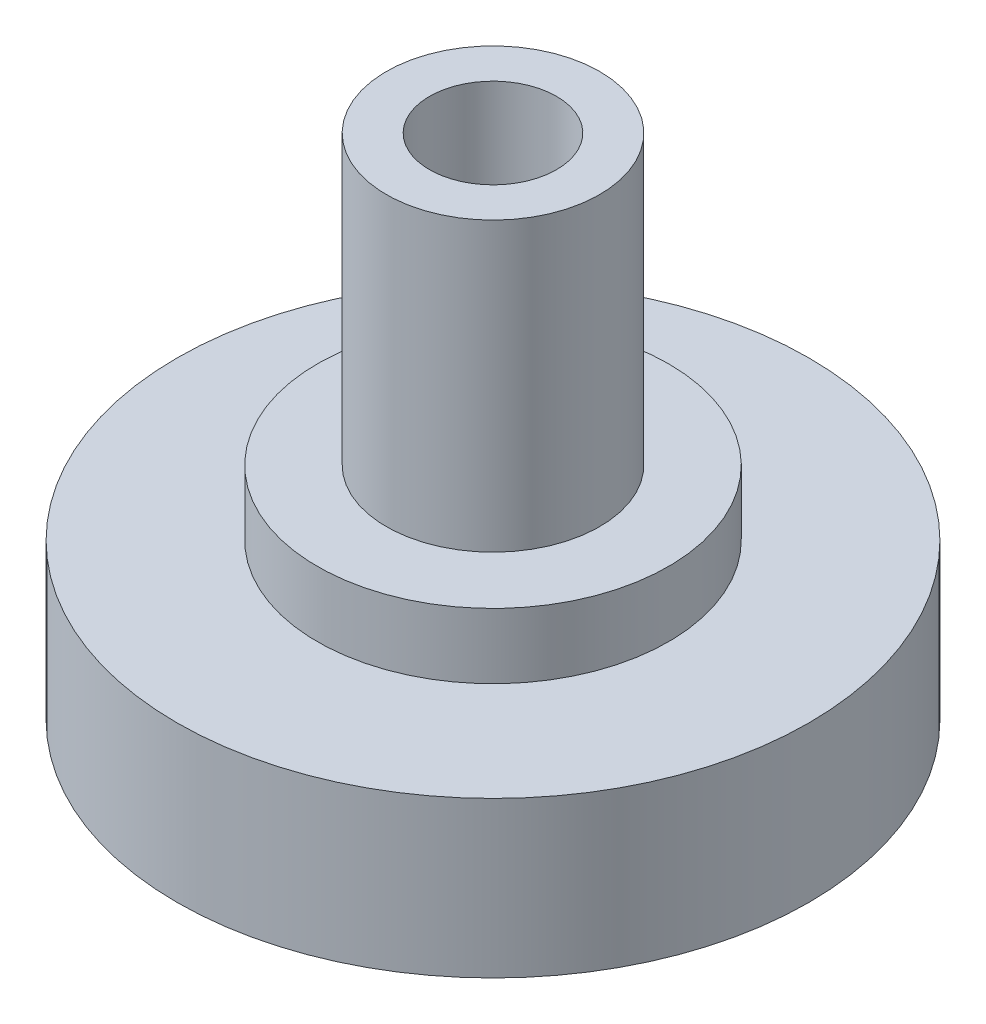
from build123d import *


with BuildPart() as part:
    # Sketch1 → Revolve1 (revolve)
    with BuildSketch(Plane.XY):
        Polygon((0, 0), (9.45, 0), (9.45, 4.65), (5.25, 4.65), (5.25, 6.6), (3.19, 6.6), (3.19, 15.2), (1.9, 15.2), (1.9, 10.2), (0, 10.2), align=None)
    revolve(axis=Axis((0, 0, 0), (0, 1, 0)))


solid = part.part
